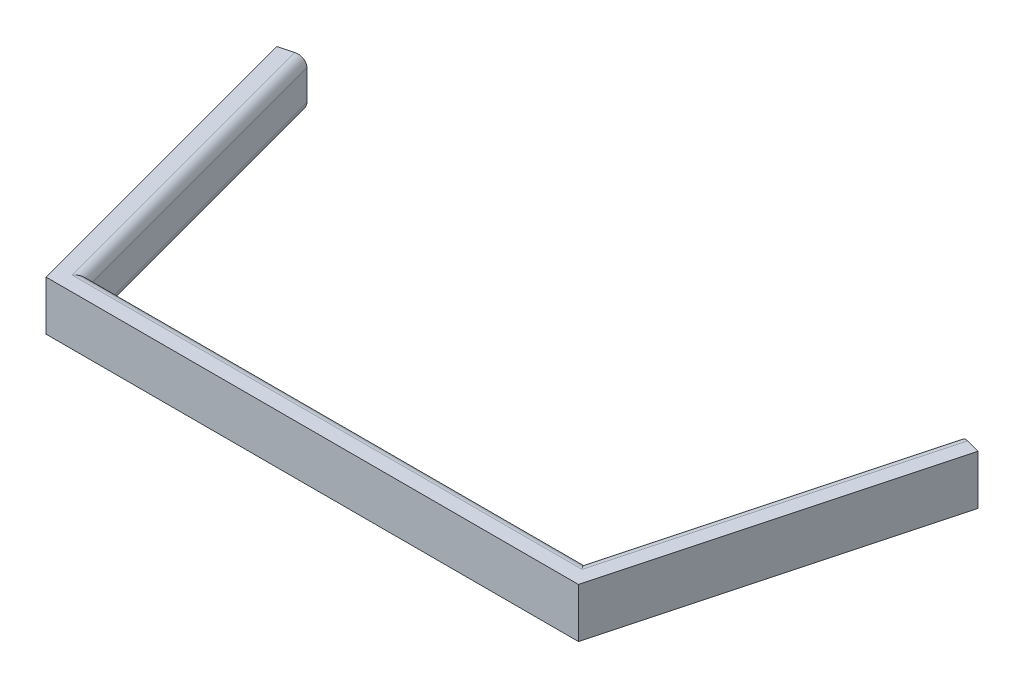
from build123d import *

# Parameters (mm, degrees)
EXTRUDE1_DEPTH = 12.7
FILLET1_R      = 2.54


with BuildPart() as part:
    # Sketch1 → Extrude1 (new body)
    with BuildSketch(Plane(origin=(0, 0, 0), x_dir=(1, 0, 0), z_dir=(0, 1, 0))):
        Polygon((-63.5, 0), (-83.917728463, 76.2), (-90.05135746, 74.556499064), (-68.372526374, -6.35), (0, -6.35), (0, 0), align=None)
        Polygon((63.5, 0), (0, 0), (0, -6.35), (68.372526374, -6.35), (90.05135746, 74.556499064), (83.917728463, 76.2), align=None)
    extrude(amount=EXTRUDE1_DEPTH)

    # Fillet1
    fillet1_edges = [part.edges().sort_by_distance(p)[0] for p in [
        (73.708864232, 12.7, -38.1),
        (0, 12.7, 0),
        (-73.708864232, 12.7, -38.1),
        (-73.708864232, 0, -38.1),
        (0, 0, 0),
        (73.708864232, 0, -38.1),
    ]]
    fillet(fillet1_edges, radius=FILLET1_R)


solid = part.part
